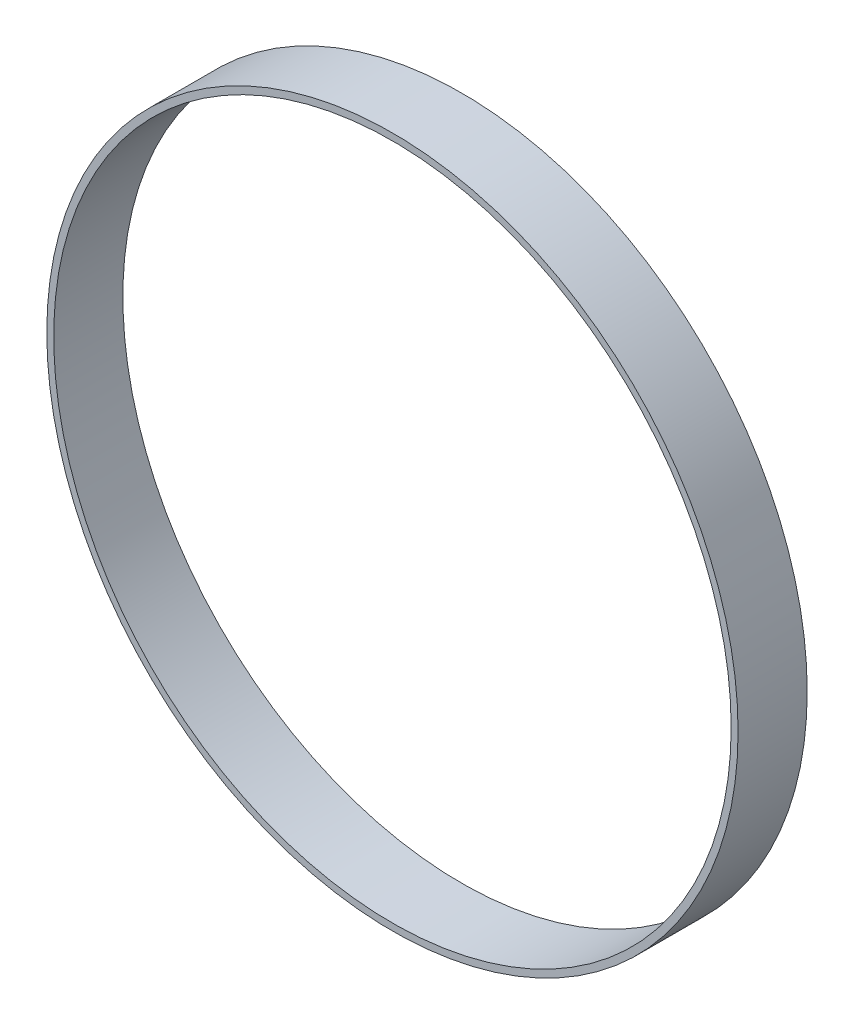
from build123d import *

# Parameters (mm, degrees)
SKETCH1_R           = 100
SKETCH1_R_2         = 98
BOSS_EXTRUDE1_DEPTH = 20


with BuildPart() as part:
    # Sketch1 → Boss-Extrude1 (new body)
    with BuildSketch(Plane.XY):
        Circle(SKETCH1_R)
        Circle(SKETCH1_R_2, mode=Mode.SUBTRACT)
    extrude(amount=BOSS_EXTRUDE1_DEPTH)


solid = part.part
